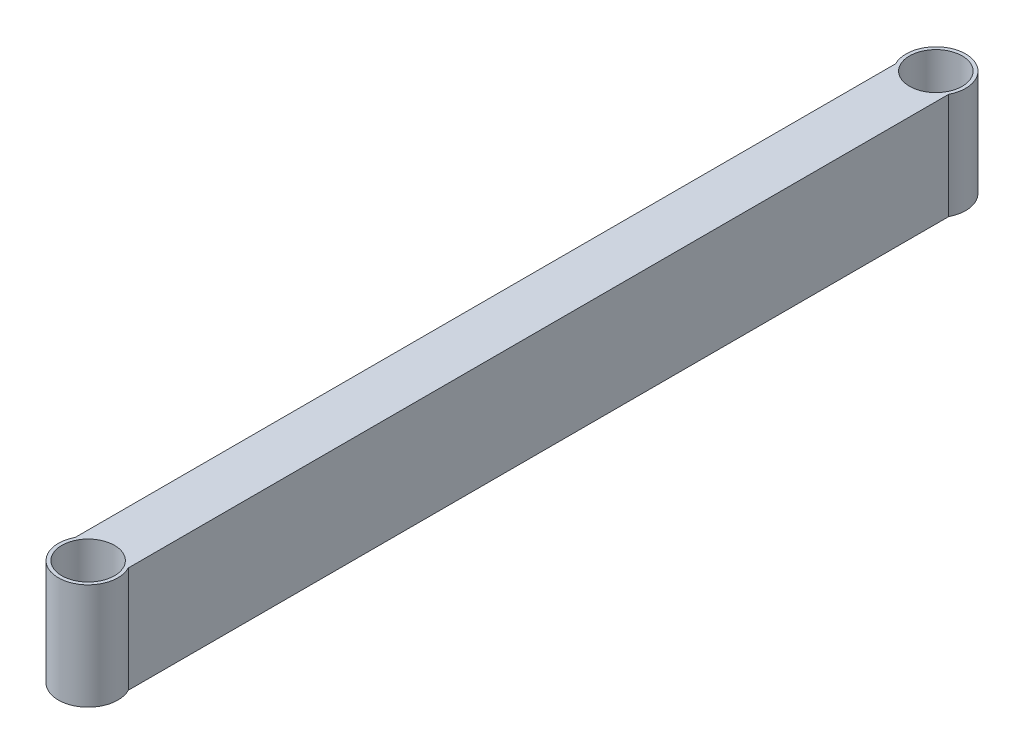
from build123d import *

# Parameters (mm, degrees)
SKETCH1_W           = 25.4
SKETCH1_H           = 50.8
SKETCH1_W_2         = 22.2504
SKETCH1_H_2         = 47.6504
BOSS_EXTRUDE1_DEPTH = 406.4
SKETCH2_R           = 14.2875
CUT_EXTRUDE1_DEPTH  = 410.759551445
SKETCH3_R           = 14.2875
SKETCH3_R_2         = 12.6365
BOSS_EXTRUDE2_DEPTH = 50.8


with BuildPart() as part:
    # Sketch1 → Boss-Extrude1 (new body)
    with BuildSketch(Plane.XY):
        Rectangle(SKETCH1_W, SKETCH1_H)
        Rectangle(SKETCH1_W_2, SKETCH1_H_2, mode=Mode.SUBTRACT)
    extrude(amount=BOSS_EXTRUDE1_DEPTH)

    # Sketch2 → Cut-Extrude1 (cut, through all)
    with BuildSketch(Plane(origin=(0, 25.4, 0), x_dir=(1, 0, 0), z_dir=(0, 1, 0))):
        Circle(SKETCH2_R)
        with Locations((0, -406.4)):
            Circle(SKETCH2_R)
    extrude(amount=-CUT_EXTRUDE1_DEPTH, mode=Mode.SUBTRACT)

    # Sketch3 → Boss-Extrude2 (add)
    # profile 1 of 2: a face of its own
    with BuildSketch(Plane(origin=(0, 25.4, 0), x_dir=(1, 0, 0), z_dir=(0, 1, 0))):
        Circle(SKETCH3_R)
        Circle(SKETCH3_R_2, mode=Mode.SUBTRACT)
    # profile 2 of 2: a face of its own
    with BuildSketch(Plane(origin=(0, 25.4, 0), x_dir=(1, 0, 0), z_dir=(0, 1, 0))):
        with Locations((0, -406.4)):
            Circle(SKETCH3_R)
        with Locations((0, -406.4)):
            Circle(SKETCH3_R_2, mode=Mode.SUBTRACT)
    extrude(amount=-BOSS_EXTRUDE2_DEPTH)


solid = part.part
